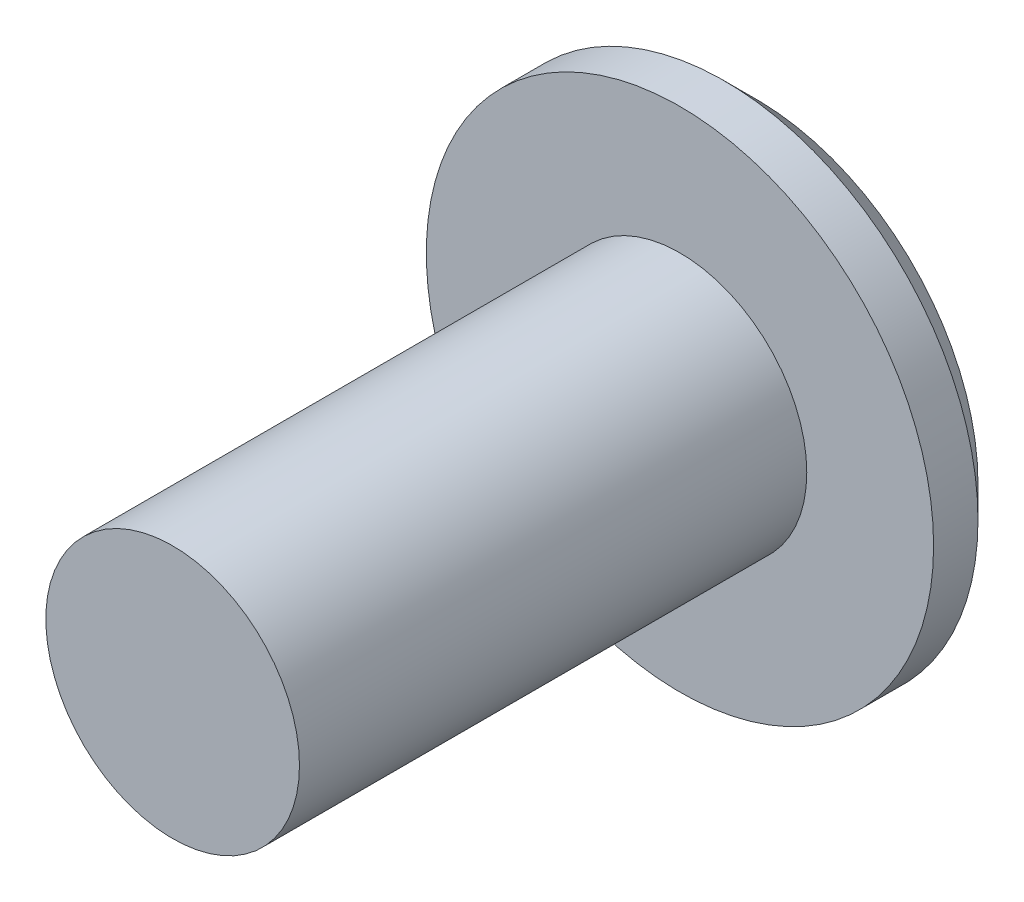
from build123d import *

# Parameters (mm, degrees)
SKETCH_1_R          = 4
EXTRUDE_1_DEPTH     = 1.2
CHAMFER_1_SIZE      = 0.5
SKETCH_3_R          = 2
EXTRUDE_2_DEPTH     = 8
CUT_EXTRUDE_1_DEPTH = 2.2


with BuildPart() as part:
    # 草图1 → 凸台-拉伸1 (new body)
    with BuildSketch(Plane.XY):
        Circle(SKETCH_1_R)
    extrude(amount=EXTRUDE_1_DEPTH)

    # 倒角1
    chamfer_1_edges = [part.edges().sort_by_distance(p)[0] for p in [
        (-4, 0, 0),
    ]]
    chamfer(chamfer_1_edges, length=CHAMFER_1_SIZE)

    # 草图3 → 凸台-拉伸2 (add)
    with BuildSketch(Plane.XY.offset(1.2)):
        Circle(SKETCH_3_R)
    extrude(amount=EXTRUDE_2_DEPTH)

    # 草图4 → 切除-拉伸1 (cut)
    with BuildSketch(Plane(origin=(0, 0, 0), x_dir=(-1, 0, 0), z_dir=(0, 0, -1))):
        Polygon((0, 1.443375673), (-1.25, 0.721687836), (-1.25, -0.721687836), (0, -1.443375673), (1.25, -0.721687836), (1.25, 0.721687836), align=None)
    extrude(amount=-CUT_EXTRUDE_1_DEPTH, mode=Mode.SUBTRACT)


solid = part.part
